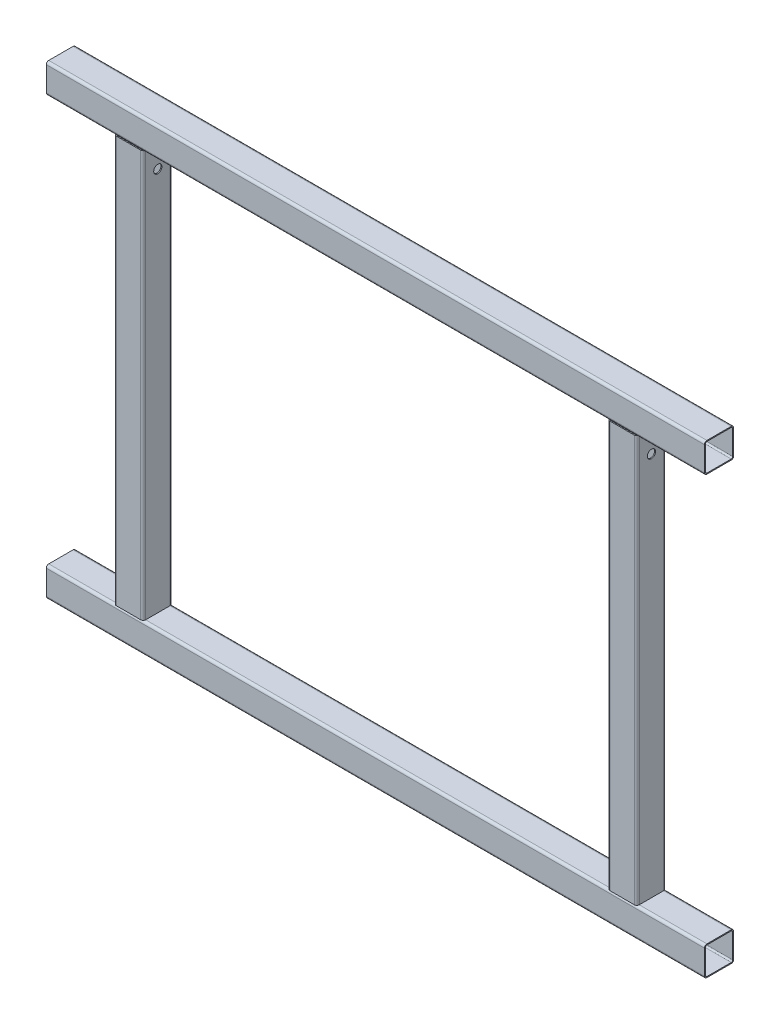
from build123d import *

# Parameters (mm, degrees)
STRUCTURAL_MEMBER1_DEPTH   = 800
STRUCTURAL_MEMBER1_2_DEPTH = 800
STRUCTURAL_MEMBER1_3_DEPTH = 532
STRUCTURAL_MEMBER1_4_DEPTH = 532
SKETCH12_R                 = 5
CUT_EXTRUDE1_DEPTH         = 679.529056121
CUT_EXTRUDE1_DEPTH_BACK    = 679.529056121


with BuildPart() as part:
    # Sketch11 → Structural Member1 (new body)
    with BuildSketch(Plane(origin=(-400, 530, 0), x_dir=(0, 1, 0), z_dir=(1, 0, 0))):
        with BuildLine():
            Line((-14.8, -17.8), (14.8, -17.8))
            ThreePointArc((14.8, -17.8), (16.921320344, -16.921320344), (17.8, -14.8))
            Line((17.8, -14.8), (17.8, 14.8))
            ThreePointArc((17.8, 14.8), (16.921320344, 16.921320344), (14.8, 17.8))
            Line((14.8, 17.8), (-14.8, 17.8))
            ThreePointArc((-14.8, 17.8), (-16.921320344, 16.921320344), (-17.8, 14.8))
            Line((-17.8, 14.8), (-17.8, -14.8))
            ThreePointArc((-17.8, -14.8), (-16.921320344, -16.921320344), (-14.8, -17.8))
        make_face()
        with BuildLine():
            Line((-14.8, 16.6), (14.8, 16.6))
            ThreePointArc((14.8, 16.6), (16.072792206, 16.072792206), (16.6, 14.8))
            Line((16.6, 14.8), (16.6, -14.8))
            ThreePointArc((16.6, -14.8), (16.072792206, -16.072792206), (14.8, -16.6))
            Line((14.8, -16.6), (-14.8, -16.6))
            ThreePointArc((-14.8, -16.6), (-16.072792206, -16.072792206), (-16.6, -14.8))
            Line((-16.6, -14.8), (-16.6, 14.8))
            ThreePointArc((-16.6, 14.8), (-16.072792206, 16.072792206), (-14.8, 16.6))
        make_face(mode=Mode.SUBTRACT)
    extrude(amount=STRUCTURAL_MEMBER1_DEPTH)


with BuildPart() as body_2:
    # Sketch11 on segment 2 (carried to segment 2) → Structural Member1 2 (new body)
    with BuildSketch(Plane.YZ.offset(-400)):
        with BuildLine():
            Line((-14.8, -17.8), (14.8, -17.8))
            ThreePointArc((14.8, -17.8), (16.921320344, -16.921320344), (17.8, -14.8))
            Line((17.8, -14.8), (17.8, 14.8))
            ThreePointArc((17.8, 14.8), (16.921320344, 16.921320344), (14.8, 17.8))
            Line((14.8, 17.8), (-14.8, 17.8))
            ThreePointArc((-14.8, 17.8), (-16.921320344, 16.921320344), (-17.8, 14.8))
            Line((-17.8, 14.8), (-17.8, -14.8))
            ThreePointArc((-17.8, -14.8), (-16.921320344, -16.921320344), (-14.8, -17.8))
        make_face()
        with BuildLine():
            Line((-14.8, 16.6), (14.8, 16.6))
            ThreePointArc((14.8, 16.6), (16.072792206, 16.072792206), (16.6, 14.8))
            Line((16.6, 14.8), (16.6, -14.8))
            ThreePointArc((16.6, -14.8), (16.072792206, -16.072792206), (14.8, -16.6))
            Line((14.8, -16.6), (-14.8, -16.6))
            ThreePointArc((-14.8, -16.6), (-16.072792206, -16.072792206), (-16.6, -14.8))
            Line((-16.6, -14.8), (-16.6, 14.8))
            ThreePointArc((-16.6, 14.8), (-16.072792206, 16.072792206), (-14.8, 16.6))
        make_face(mode=Mode.SUBTRACT)
    extrude(amount=STRUCTURAL_MEMBER1_2_DEPTH)


with BuildPart() as body_3:
    # Sketch11 on segment 3 (carried to segment 3) → Structural Member1 3 (new body)
    with BuildSketch(Plane(origin=(-300, 531, 0), x_dir=(1, 0, 0), z_dir=(0, -1, 0))):
        with BuildLine():
            Line((-14.8, -17.8), (14.8, -17.8))
            ThreePointArc((14.8, -17.8), (16.921320344, -16.921320344), (17.8, -14.8))
            Line((17.8, -14.8), (17.8, 14.8))
            ThreePointArc((17.8, 14.8), (16.921320344, 16.921320344), (14.8, 17.8))
            Line((14.8, 17.8), (-14.8, 17.8))
            ThreePointArc((-14.8, 17.8), (-16.921320344, 16.921320344), (-17.8, 14.8))
            Line((-17.8, 14.8), (-17.8, -14.8))
            ThreePointArc((-17.8, -14.8), (-16.921320344, -16.921320344), (-14.8, -17.8))
        make_face()
        with BuildLine():
            Line((-14.8, 16.6), (14.8, 16.6))
            ThreePointArc((14.8, 16.6), (16.072792206, 16.072792206), (16.6, 14.8))
            Line((16.6, 14.8), (16.6, -14.8))
            ThreePointArc((16.6, -14.8), (16.072792206, -16.072792206), (14.8, -16.6))
            Line((14.8, -16.6), (-14.8, -16.6))
            ThreePointArc((-14.8, -16.6), (-16.072792206, -16.072792206), (-16.6, -14.8))
            Line((-16.6, -14.8), (-16.6, 14.8))
            ThreePointArc((-16.6, 14.8), (-16.072792206, 16.072792206), (-14.8, 16.6))
        make_face(mode=Mode.SUBTRACT)
    extrude(amount=STRUCTURAL_MEMBER1_3_DEPTH)

    # Structural Member1 3 end butt 1
    split(bisect_by=Plane(origin=(-300, 512.2, 0), x_dir=(1, 0, 0), z_dir=(0, -1, 0)), keep=Keep.TOP)

    # Structural Member1 3 end butt 2
    split(bisect_by=Plane(origin=(-300, 17.8, 0), x_dir=(-1, 0, 0), z_dir=(0, 1, 0)), keep=Keep.TOP)


with BuildPart() as body_4:
    # Sketch11 on segment 4 (carried to segment 4) → Structural Member1 4 (new body)
    with BuildSketch(Plane(origin=(300, 531, 0), x_dir=(1, 0, 0), z_dir=(0, -1, 0))):
        with BuildLine():
            Line((-14.8, -17.8), (14.8, -17.8))
            ThreePointArc((14.8, -17.8), (16.921320344, -16.921320344), (17.8, -14.8))
            Line((17.8, -14.8), (17.8, 14.8))
            ThreePointArc((17.8, 14.8), (16.921320344, 16.921320344), (14.8, 17.8))
            Line((14.8, 17.8), (-14.8, 17.8))
            ThreePointArc((-14.8, 17.8), (-16.921320344, 16.921320344), (-17.8, 14.8))
            Line((-17.8, 14.8), (-17.8, -14.8))
            ThreePointArc((-17.8, -14.8), (-16.921320344, -16.921320344), (-14.8, -17.8))
        make_face()
        with BuildLine():
            Line((-14.8, 16.6), (14.8, 16.6))
            ThreePointArc((14.8, 16.6), (16.072792206, 16.072792206), (16.6, 14.8))
            Line((16.6, 14.8), (16.6, -14.8))
            ThreePointArc((16.6, -14.8), (16.072792206, -16.072792206), (14.8, -16.6))
            Line((14.8, -16.6), (-14.8, -16.6))
            ThreePointArc((-14.8, -16.6), (-16.072792206, -16.072792206), (-16.6, -14.8))
            Line((-16.6, -14.8), (-16.6, 14.8))
            ThreePointArc((-16.6, 14.8), (-16.072792206, 16.072792206), (-14.8, 16.6))
        make_face(mode=Mode.SUBTRACT)
    extrude(amount=STRUCTURAL_MEMBER1_4_DEPTH)

    # Structural Member1 4 end butt 1
    split(bisect_by=Plane(origin=(300, 512.2, 0), x_dir=(1, 0, 0), z_dir=(0, -1, 0)), keep=Keep.TOP)

    # Structural Member1 4 end butt 2
    split(bisect_by=Plane(origin=(300, 17.8, 0), x_dir=(-1, 0, 0), z_dir=(0, 1, 0)), keep=Keep.TOP)


with BuildPart() as cut_extrude1_tool:
    # Sketch12 → Cut-Extrude1 (new, two sides)
    with BuildSketch(Plane(origin=(0, 0, 0), x_dir=(0, 0, -1), z_dir=(1, 0, 0))) as cut_extrude1_sk:
        with Locations(Location((0, 485, 0), (0, 0, 90))):
            Circle(SKETCH12_R)
    extrude(amount=CUT_EXTRUDE1_DEPTH)
    extrude(cut_extrude1_sk.sketch, amount=-CUT_EXTRUDE1_DEPTH_BACK)


with BuildPart() as body_3_1:
    add(body_3.part)

    # Cut-Extrude1: cut by cut_extrude1_tool
    add(cut_extrude1_tool.part, mode=Mode.SUBTRACT)


with BuildPart() as body_4_1:
    add(body_4.part)

    # Cut-Extrude1: cut by cut_extrude1_tool
    add(cut_extrude1_tool.part, mode=Mode.SUBTRACT)


solid = Compound([part.part, body_2.part, body_3_1.part, body_4_1.part])
